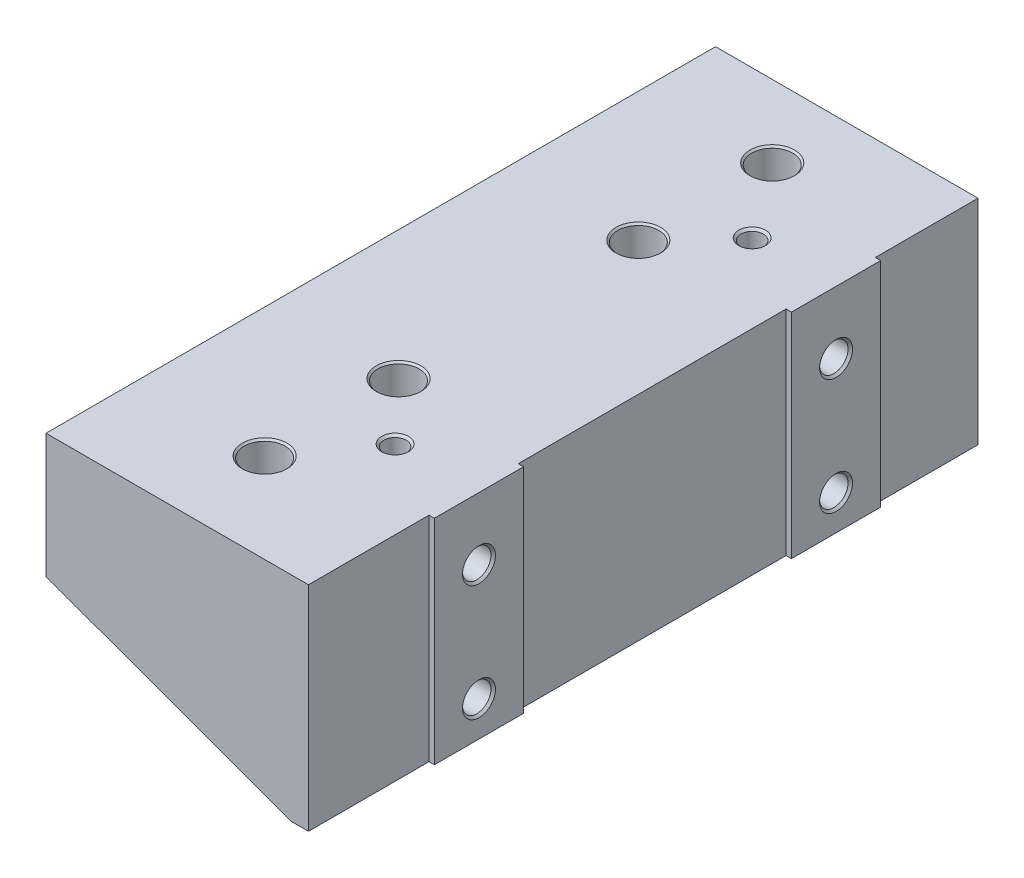
from build123d import *

# Parameters (mm, degrees)
EXTRUDE1_DEPTH                              = 95.25
TAPPED_HOLE_FOR_3_8_16_HELICOIL1_AT_2_COUNT = 2
TAPPED_HOLE_FOR_3_8_16_HELICOIL1_AT_2_PITCH = 38.1
TAPPED_HOLE_FOR_3_8_16_HELICOIL1_AT_3_COUNT = 2
TAPPED_HOLE_FOR_3_8_16_HELICOIL1_AT_3_PITCH = 106.3244
TAPPED_HOLE_FOR_3_8_16_HELICOIL1_AT_4_COUNT = 2
TAPPED_HOLE_FOR_3_8_16_HELICOIL1_AT_4_PITCH = 144.4244
TAPPED_HOLE_FOR_1_4_20_HELICOIL1_AT_2_COUNT = 2
TAPPED_HOLE_FOR_1_4_20_HELICOIL1_AT_2_PITCH = 33.02
TAPPED_HOLE_FOR_1_4_20_HELICOIL1_AT_3_COUNT = 2
TAPPED_HOLE_FOR_1_4_20_HELICOIL1_AT_3_PITCH = 106.831083492
TAPPED_HOLE_FOR_1_4_20_HELICOIL1_AT_4_COUNT = 2
TAPPED_HOLE_FOR_1_4_20_HELICOIL1_AT_4_PITCH = 101.6
F_1_4_0_25_DIAMETER_HOLE1_D                 = 6.35
F_1_4_0_25_DIAMETER_HOLE1_CSINK_D           = 7.62
F_1_4_0_25_DIAMETER_HOLE1_CSINK_ANGLE       = 90
SKETCH20_W                                  = 76.2
SKETCH20_H                                  = 60.757213881
SKETCH20_W_2                                = 29.21
SKETCH20_W_3                                = 34.29
EXTRUDE2_DEPTH                              = 1.524


with BuildPart() as part:
    # Sketch13 → Extrude1 (new body, symmetric)
    with BuildSketch(Plane.XY):
        Polygon((0, -60.757213881), (-6.35, -60.757213881), (-76.2, -35.333893017), (-76.2, 0), (0, 0), align=None)
    extrude(amount=EXTRUDE1_DEPTH, both=True)

    # Sketch14 → Tapped Hole for 3/8-16 Helicoil1 (revolve, cut)
    with BuildSketch(Plane(origin=(-39.497, 0, 69.7484), x_dir=(0, 0, 1), z_dir=(1, 0, 0))):
        Polygon((0, 0), (0, 60.757213881), (5.0419, 60.757213881), (5.0419, 28.702), (5.84454, 28.702), (5.84454, 0.50546), (6.35, 0), align=None)
    tapped_hole_for_3_8_16_helicoil1 = revolve(axis=Axis((-39.497, 6.35, 69.7484), (0, -1, 0)), mode=Mode.SUBTRACT)

    # Tapped Hole for 3/8-16 Helicoil1 at 2: Tapped Hole for 3/8-16 Helicoil1 ×2
    with Locations(*[(0, 0, -i * TAPPED_HOLE_FOR_3_8_16_HELICOIL1_AT_2_PITCH) for i in range(1, TAPPED_HOLE_FOR_3_8_16_HELICOIL1_AT_2_COUNT)]):
        add(tapped_hole_for_3_8_16_helicoil1, mode=Mode.SUBTRACT)

    # Tapped Hole for 3/8-16 Helicoil1 at 3: Tapped Hole for 3/8-16 Helicoil1 ×2
    with Locations(*[(0, 0, -i * TAPPED_HOLE_FOR_3_8_16_HELICOIL1_AT_3_PITCH) for i in range(1, TAPPED_HOLE_FOR_3_8_16_HELICOIL1_AT_3_COUNT)]):
        add(tapped_hole_for_3_8_16_helicoil1, mode=Mode.SUBTRACT)

    # Tapped Hole for 3/8-16 Helicoil1 at 4: Tapped Hole for 3/8-16 Helicoil1 ×2
    with Locations(*[(0, 0, -i * TAPPED_HOLE_FOR_3_8_16_HELICOIL1_AT_4_PITCH) for i in range(1, TAPPED_HOLE_FOR_3_8_16_HELICOIL1_AT_4_COUNT)]):
        add(tapped_hole_for_3_8_16_helicoil1, mode=Mode.SUBTRACT)

    # Sketch16 → Tapped Hole for 1/4-20 Helicoil1 (revolve, cut)
    with BuildSketch(Plane(origin=(0, -17.78, 48.26), x_dir=(0, 0, -1), z_dir=(0, 1, 0))):
        Polygon((0, 0), (0, 25.905827343), (3.3782, 23.876), (3.3782, 15.748), (4.04749, 15.748), (4.04749, 0.635), (4.68249, 0), align=None)
    tapped_hole_for_1_4_20_helicoil1 = revolve(axis=Axis((6.35, -17.78, 48.26), (-1, 0, 0)), mode=Mode.SUBTRACT)

    # Tapped Hole for 1/4-20 Helicoil1 at 2: Tapped Hole for 1/4-20 Helicoil1 ×2
    with Locations(*[(0, -i * TAPPED_HOLE_FOR_1_4_20_HELICOIL1_AT_2_PITCH, 0) for i in range(1, TAPPED_HOLE_FOR_1_4_20_HELICOIL1_AT_2_COUNT)]):
        add(tapped_hole_for_1_4_20_helicoil1, mode=Mode.SUBTRACT)

    # Tapped Hole for 1/4-20 Helicoil1 at 3: Tapped Hole for 1/4-20 Helicoil1 ×2
    with Locations(*[Vector(0, -0.309086072, -0.951034069) * (i * TAPPED_HOLE_FOR_1_4_20_HELICOIL1_AT_3_PITCH) for i in range(1, TAPPED_HOLE_FOR_1_4_20_HELICOIL1_AT_3_COUNT)]):
        add(tapped_hole_for_1_4_20_helicoil1, mode=Mode.SUBTRACT)

    # Tapped Hole for 1/4-20 Helicoil1 at 4: Tapped Hole for 1/4-20 Helicoil1 ×2
    with Locations(*[(0, 0, -i * TAPPED_HOLE_FOR_1_4_20_HELICOIL1_AT_4_PITCH) for i in range(1, TAPPED_HOLE_FOR_1_4_20_HELICOIL1_AT_4_COUNT)]):
        add(tapped_hole_for_1_4_20_helicoil1, mode=Mode.SUBTRACT)

    # 1/4 (0.25) Diameter Hole1 (through all)
    with Locations(Plane(origin=(0, 0, 0), x_dir=(-1, 0, 0), z_dir=(0, 1, 0))):
        with Locations((23.876, -53.34), (23.876, 48.26)):
            CounterSinkHole(F_1_4_0_25_DIAMETER_HOLE1_D / 2, F_1_4_0_25_DIAMETER_HOLE1_CSINK_D / 2, counter_sink_angle=F_1_4_0_25_DIAMETER_HOLE1_CSINK_ANGLE)

    # Sketch20 → Extrude2 (cut)
    with BuildSketch(Plane(origin=(0, 0, 0), x_dir=(0, 0, -1), z_dir=(1, 0, 0))):
        with Locations((2.54, -30.378606941)):
            Rectangle(SKETCH20_W, SKETCH20_H)
        with Locations((80.645, -30.378606941)):
            Rectangle(SKETCH20_W_2, SKETCH20_H)
        with Locations((-78.105, -30.378606941)):
            Rectangle(SKETCH20_W_3, SKETCH20_H)
    extrude(amount=-EXTRUDE2_DEPTH, mode=Mode.SUBTRACT)


solid = part.part
